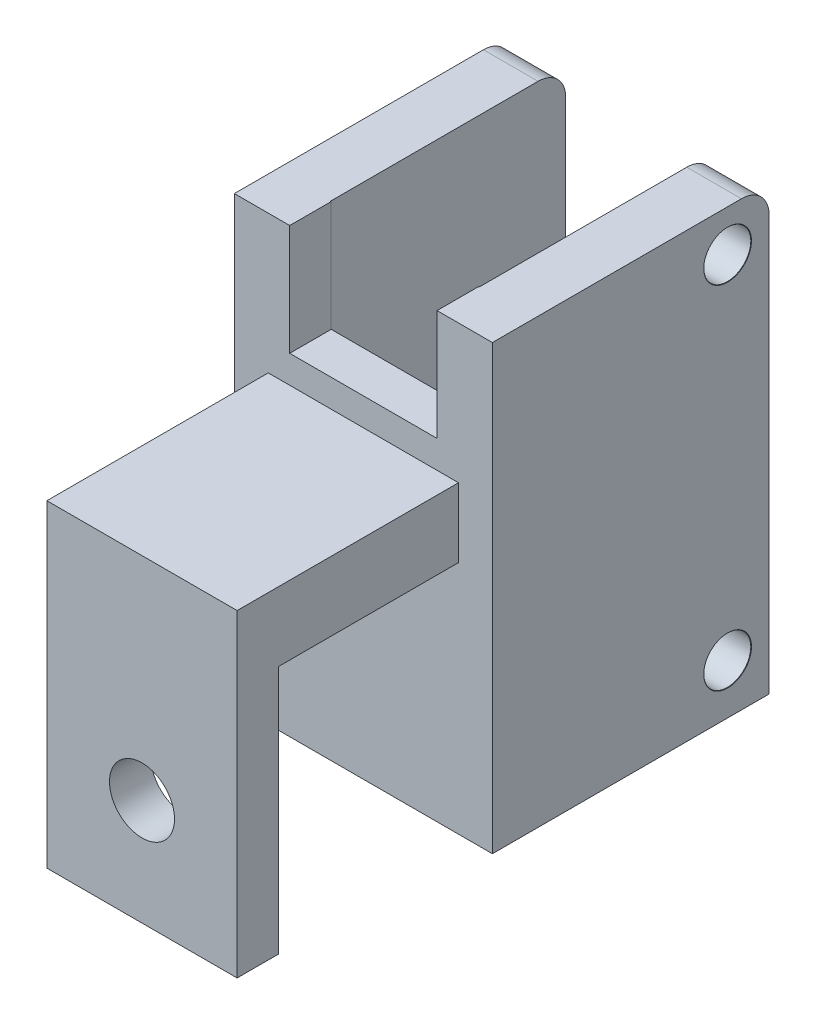
from build123d import *

# Parameters (mm, degrees)
SKETCH_1_W                   = 18.65
SKETCH_1_H                   = 32
EXTRUDE_1_DEPTH              = 20
SKETCH_2_W                   = 10.75
SKETCH_2_H                   = 32
CUT_EXTRUDE_2_DEPTH          = 17
CUT_EXTRUDE_3_REACH          = 22
SKETCH_4_W                   = 10.65
SKETCH_4_H                   = 8
FILLET_1_R                   = 2
HOLE_WIZARD_M3_4_D           = 3.4
HOLE_WIZARD_M3_4_DEPTH       = 3.95
HOLE_WIZARD_M3_4_CSINK_D     = 3.45
HOLE_WIZARD_M3_4_CSINK_ANGLE = 92
SKETCH_18_W                  = 13.75
SKETCH_18_H                  = 5
EXTRUDE_2_DEPTH              = 16
SKETCH_19_W                  = 13.75
SKETCH_19_H                  = 3
EXTRUDE_3_DEPTH              = 18
CUT_EXTRUDE_4_REACH          = 38
SKETCH_20_R                  = 2.35


with BuildPart() as part:
    # 스케치1 → 보스-돌출1 (new body)
    with BuildSketch(Plane.XY):
        Rectangle(SKETCH_1_W, SKETCH_1_H)
    extrude(amount=-EXTRUDE_1_DEPTH)

    # 스케치2 → 컷-돌출2 (cut)
    with BuildSketch(Plane(origin=(0, 0, -20), x_dir=(-1, 0, 0), z_dir=(0, 0, -1))):
        Rectangle(SKETCH_2_W, SKETCH_2_H)
    extrude(amount=-CUT_EXTRUDE_2_DEPTH, mode=Mode.SUBTRACT)

    # 스케치4 → 컷-돌출3 (cut, up to next)
    with BuildSketch(Plane.XY, mode=Mode.PRIVATE) as cut_extrude_3_sk1:
        with Locations((0, 12)):
            Rectangle(SKETCH_4_W, SKETCH_4_H)
    cut_extrude_3_tool1 = extrude(cut_extrude_3_sk1.sketch, amount=-CUT_EXTRUDE_3_REACH, mode=Mode.PRIVATE) & part.part
    add(cut_extrude_3_tool1.solids().sort_by_distance((0, 12, 0))[0], mode=Mode.SUBTRACT)

    # 필렛1
    fillet_1_edges = [part.edges().sort_by_distance(p)[0] for p in [
        (-7.35, 16, -20),
        (7.35, 16, -20),
    ]]
    fillet(fillet_1_edges, radius=FILLET_1_R)

    # M3 여유 구멍4
    with Locations(Plane(origin=(9.325, 0, 0), x_dir=(0, 0, -1), z_dir=(1, 0, 0))):
        with Locations((17, 13), (17, -12.4), (38.233038072, 15.712174446)):
            CounterSinkHole(HOLE_WIZARD_M3_4_D / 2, HOLE_WIZARD_M3_4_CSINK_D / 2, depth=HOLE_WIZARD_M3_4_DEPTH, counter_sink_angle=HOLE_WIZARD_M3_4_CSINK_ANGLE)

    # 스케치18 → 보스-돌출2 (add)
    with BuildSketch(Plane.XY):
        with Locations((0, 3.5)):
            Rectangle(SKETCH_18_W, SKETCH_18_H)
    extrude(amount=EXTRUDE_2_DEPTH)

    # 스케치19 → 보스-돌출3 (add)
    with BuildSketch(Plane.XZ.offset(-1)):
        with Locations((0, 14.5)):
            Rectangle(SKETCH_19_W, SKETCH_19_H)
    extrude(amount=EXTRUDE_3_DEPTH)

    # 스케치20 → 컷-돌출4 (cut, up to next)
    with BuildSketch(Plane.XY.offset(16), mode=Mode.PRIVATE) as cut_extrude_4_sk1:
        with Locations((0, -9.320578261)):
            Circle(SKETCH_20_R)
    cut_extrude_4_tool1 = extrude(cut_extrude_4_sk1.sketch, amount=-CUT_EXTRUDE_4_REACH, mode=Mode.PRIVATE) & part.part
    add(cut_extrude_4_tool1.solids().sort_by_distance((0, -9.320578, 16))[0], mode=Mode.SUBTRACT)


solid = part.part
